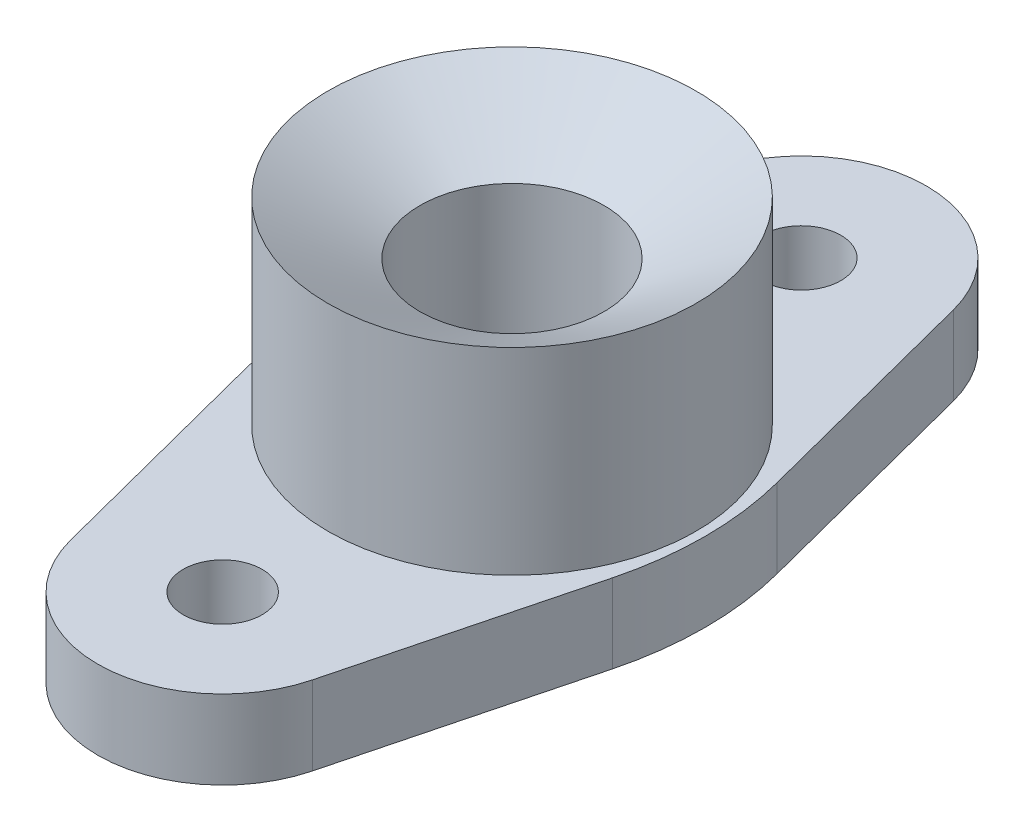
from build123d import *

# Parameters (mm, degrees)
SKETCH1_R           = 6
BOSS_EXTRUDE1_DEPTH = 6
FILLET1_R           = 50
SKETCH4_R           = 28
SKETCH4_R_2         = 14
BOSS_EXTRUDE3_DEPTH = 30
SKETCH4_2_R         = 14
CUT_EXTRUDE1_DEPTH  = 76.701912882


with BuildPart() as part:
    # Sketch1 → Boss-Extrude1 (new, symmetric)
    with BuildSketch(Plane(origin=(0, 0, 0), x_dir=(1, 0, 0), z_dir=(0, 1, 0))):
        with BuildLine():
            ThreePointArc((18.395196505, 48.755706629), (0, 63), (-18.395196505, 48.755706629))
            Line((-18.395196505, 48.755706629), (-31, 0))
            Line((-31, 0), (-18.395196505, -48.755706629))
            ThreePointArc((-18.395196505, -48.755706629), (0, -63), (18.395196505, -48.755706629))
            Line((18.395196505, -48.755706629), (31, 0))
            Line((31, 0), (18.395196505, 48.755706629))
        make_face()
        with Locations((0, 44)):
            Circle(SKETCH1_R, mode=Mode.SUBTRACT)
        with Locations((0, -44)):
            Circle(SKETCH1_R, mode=Mode.SUBTRACT)
    extrude(amount=BOSS_EXTRUDE1_DEPTH, both=True)

    # Fillet1
    fillet1_edges = [part.edges().sort_by_distance(p)[0] for p in [
        (-31, 0, 0),
        (31, 0, 0),
    ]]
    fillet(fillet1_edges, radius=FILLET1_R)

    # Sketch4 → Boss-Extrude3 (add)
    with BuildSketch(Plane(origin=(0, 6, 0), x_dir=(1, 0, 0), z_dir=(0, 1, 0))):
        Circle(SKETCH4_R)
        Circle(SKETCH4_R_2, mode=Mode.SUBTRACT)
    extrude(amount=BOSS_EXTRUDE3_DEPTH)

    # Sketch4_2 → Cut-Extrude1 (cut, through all)
    with BuildSketch(Plane(origin=(0, 6, 0), x_dir=(1, 0, 0), z_dir=(0, 1, 0))):
        Circle(SKETCH4_2_R)
    extrude(amount=-CUT_EXTRUDE1_DEPTH, mode=Mode.SUBTRACT)

    # Cut-Extrude3 cone 1 section (through the dimple's axis) → Cut-Extrude3 (revolve, cut)
    with BuildSketch(Plane(origin=(0, 36, 0), x_dir=(0, 0, 1), z_dir=(1, 0, 0))):
        Polygon((0, 0), (28, 0), (0, 16.165807537), align=None)
    revolve(axis=Axis((0, 36, 0), (0, -1, 0)), mode=Mode.SUBTRACT)


solid = part.part
